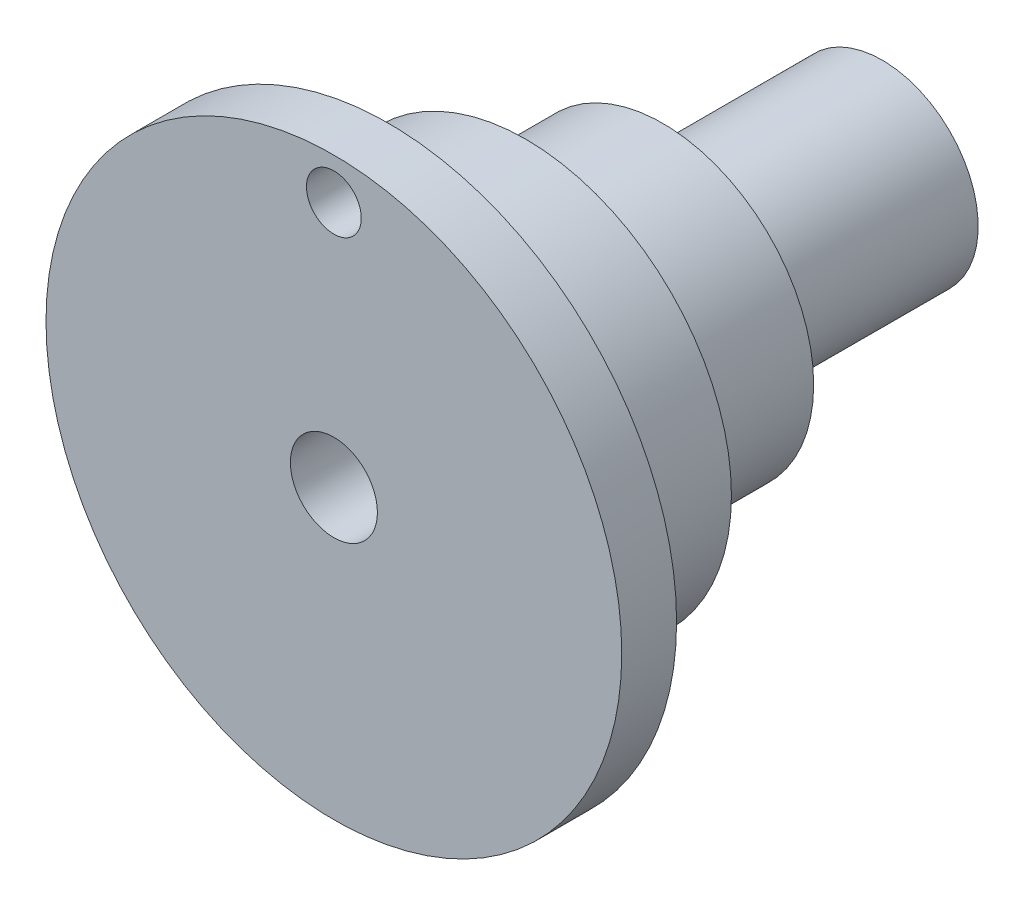
from build123d import *

# Parameters (mm, degrees)
SKETCH1_R           = 7.5
SKETCH1_R_2         = 1.5875
BOSS_EXTRUDE1_DEPTH = 20
SKETCH2_R           = 10.5
SKETCH2_R_2         = 7.5
SKETCH2_R_3         = 1.5875
BOSS_EXTRUDE2_DEPTH = 2
SKETCH3_R           = 1
CUT_EXTRUDE1_DEPTH  = 3
SKETCH4_R           = 7.5
SKETCH4_R_2         = 5.5
CUT_EXTRUDE2_DEPTH  = 13
SKETCH5_R           = 5.5
SKETCH5_R_2         = 3.5
CUT_EXTRUDE3_DEPTH  = 8


with BuildPart() as part:
    # Sketch1 → Boss-Extrude1 (new body)
    with BuildSketch(Plane.XY):
        Circle(SKETCH1_R)
        Circle(SKETCH1_R_2, mode=Mode.SUBTRACT)
    extrude(amount=BOSS_EXTRUDE1_DEPTH)

    # Sketch2 → Boss-Extrude2 (add)
    with BuildSketch(Plane.XY.offset(20)):
        Circle(SKETCH2_R)
        Circle(SKETCH2_R_2, mode=Mode.SUBTRACT)
        Circle(SKETCH2_R_2)
        Circle(SKETCH2_R_3, mode=Mode.SUBTRACT)
    extrude(amount=-BOSS_EXTRUDE2_DEPTH)

    # Sketch3 → Cut-Extrude1 (cut, through all)
    with BuildSketch(Plane(origin=(0, 0, 18), x_dir=(-1, 0, 0), z_dir=(0, 0, -1))):
        with Locations((0, 9)):
            Circle(SKETCH3_R)
    extrude(amount=-CUT_EXTRUDE1_DEPTH, mode=Mode.SUBTRACT)

    # Sketch4 → Cut-Extrude2 (cut)
    with BuildSketch(Plane(origin=(0, 0, 0), x_dir=(-1, 0, 0), z_dir=(0, 0, -1))):
        Circle(SKETCH4_R)
        Circle(SKETCH4_R_2, mode=Mode.SUBTRACT)
    extrude(amount=-CUT_EXTRUDE2_DEPTH, mode=Mode.SUBTRACT)

    # Sketch5 → Cut-Extrude3 (cut)
    with BuildSketch(Plane(origin=(0, 0, 0), x_dir=(-1, 0, 0), z_dir=(0, 0, -1))):
        Circle(SKETCH5_R)
        Circle(SKETCH5_R_2, mode=Mode.SUBTRACT)
    extrude(amount=-CUT_EXTRUDE3_DEPTH, mode=Mode.SUBTRACT)


solid = part.part
